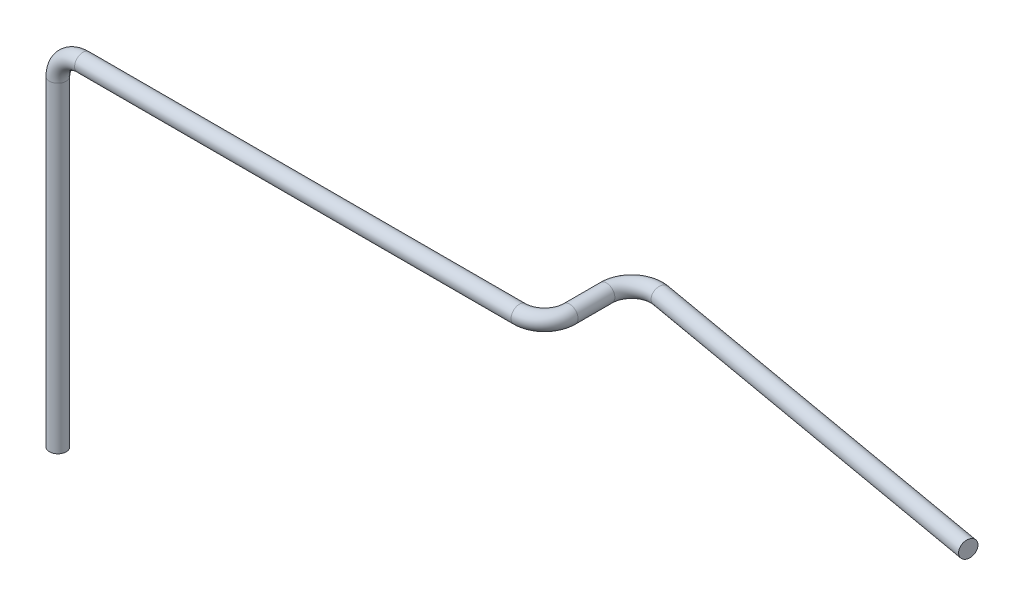
from build123d import *

# Parameters (mm, degrees)
SKETCH3_R = 0.3937


with BuildPart() as part:
    # Sweep3: sweep along a curve in space
    with BuildLine() as sweep3_path:
        Line((-15.494, 0.5969, -1.778), (-15.494, -14.478, -1.778))
        ThreePointArc((-14.3129, 1.778, -1.778), (-15.148063819, 1.432063819, -1.778), (-15.494, 0.5969, -1.778))
        Line((6.1849, 1.778, -1.778), (-14.3129, 1.778, -1.778))
        ThreePointArc((7.366, 1.778, -2.9591), (7.020063819, 1.778, -2.123936181), (6.1849, 1.778, -1.778))
        Line((7.366, 1.778, -2.9591), (7.366, 1.778, -4.6863))
        ThreePointArc((8.752195863, 1.778, -5.849456437), (7.787903554, 1.778, -5.591075092), (7.366, 1.778, -4.6863))
        Line((8.752195863, 1.778, -5.849456437), (26.289, 1.778, -2.757244712))
    # Sketch3 → Sweep3 (sweep)
    with BuildSketch(Plane(origin=(-15.494, -14.478, -1.778), x_dir=(1, 0, 0), z_dir=(0, -1, 0))):
        Circle(SKETCH3_R)
    sweep(path=sweep3_path.line)


solid = part.part
